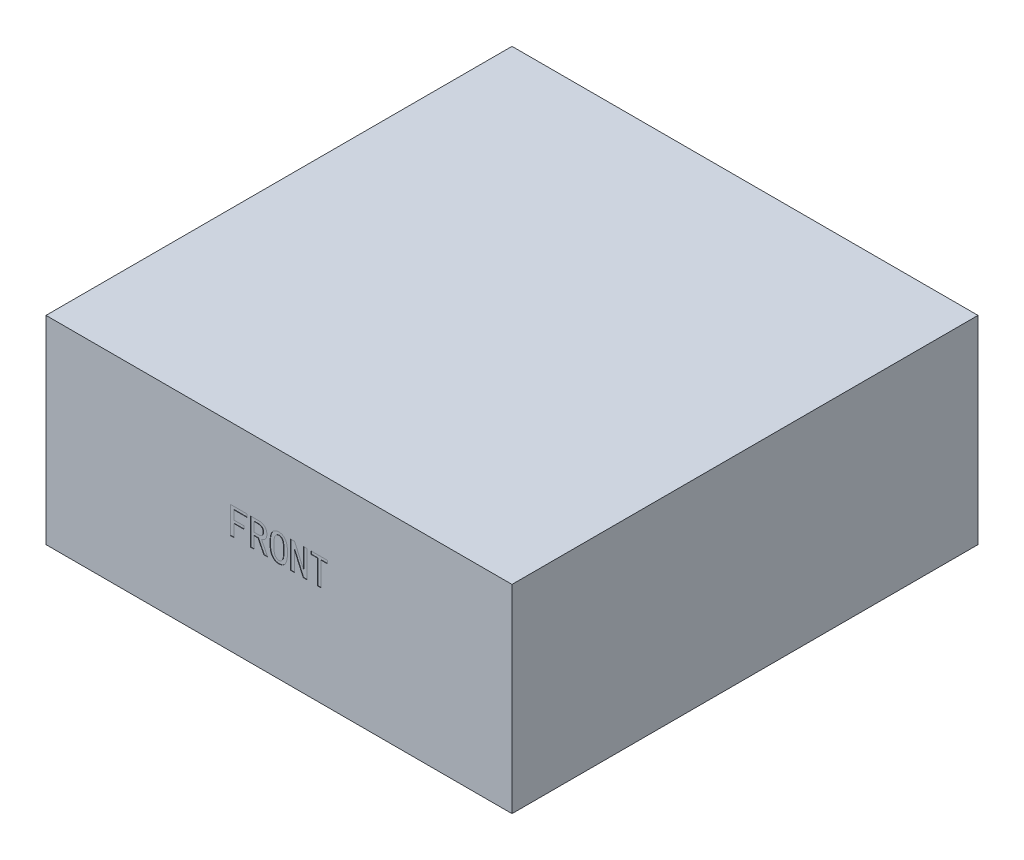
from build123d import *

# Parameters (mm, degrees)
SKETCH1_W           = 115
SKETCH1_H           = 115
BOSS_EXTRUDE1_DEPTH = 49
CUT_EXTRUDE1_DEPTH  = 0.1
SKETCH3_R           = 1.5
CUT_EXTRUDE2_DEPTH  = 10


with BuildPart() as part:
    # Sketch1 → Boss-Extrude1 (new body)
    with BuildSketch(Plane(origin=(0, 0, 0), x_dir=(1, 0, 0), z_dir=(0, 1, 0))):
        Rectangle(SKETCH1_W, SKETCH1_H)
    extrude(amount=BOSS_EXTRUDE1_DEPTH)

    # Sketch2 → Cut-Extrude1 (cut)
    with BuildSketch(Plane.XY.offset(57.5)):
        Polygon((-7.917836765, 30.623647153), (-11.116174769, 30.623647153), (-11.116174769, 28.439416321), (-8.697919205, 28.439416321), (-8.697919205, 27.698338004), (-11.116174769, 27.698338004), (-11.116174769, 24.69502061), (-12.013269574, 24.69502061), (-12.013269574, 31.364725471), (-7.917836765, 31.364725471), align=None)
        with BuildLine():
            Line((-2.808296784, 24.69502061), (-3.744395712, 24.69502061))
            Line((-3.744395712, 24.69502061), (-5.148544103, 27.581325638))
            Line((-5.148544103, 27.581325638), (-6.162651275, 27.581325638))
            Line((-6.162651275, 27.581325638), (-6.162651275, 24.69502061))
            Line((-6.162651275, 24.69502061), (-7.059746081, 24.69502061))
            Line((-7.059746081, 24.69502061), (-7.059746081, 31.364725471))
            Line((-7.059746081, 31.364725471), (-5.109539981, 31.364725471))
            add(Edge.make_bspline(
                [(-5.109539981, 31.364725471), (-5.033422241, 31.36321552), (-4.884283624, 31.36025705), (-4.665846358, 31.340727494), (-4.45885424, 31.304160913), (-4.262886168, 31.2548471), (-4.076887368, 31.193875661), (-3.903169293, 31.114522393), (-3.739054577, 31.023957299), (-3.586622204, 30.918577266), (-3.448652055, 30.797520978), (-3.327861252, 30.658008975), (-3.227422926, 30.499867995), (-3.143874152, 30.324418369), (-3.081593847, 30.131289285), (-3.03483742, 29.921040893), (-3.007693079, 29.693076761), (-3.004805189, 29.534974999), (-3.003317394, 29.453523493)],
                knots=[0, 0, 0, 0, 0.000228361, 0.00044743, 0.000657141, 0.000858251, 0.001053315, 0.00124341, 0.001430305, 0.001615044, 0.001798235, 0.001979525, 0.00216666, 0.002358574, 0.002560946, 0.002774043, 0.003003934, 0.003248224, 0.003248224, 0.003248224, 0.003248224], degree=3))
            add(Edge.make_bspline(
                [(-3.003317394, 29.453523493), (-3.004236594, 29.390390165), (-3.006030237, 29.267197519), (-3.025454571, 29.088095913), (-3.055313469, 28.91994093), (-3.097086791, 28.762601258), (-3.151593342, 28.616101913), (-3.220384865, 28.48106626), (-3.299426456, 28.356037186), (-3.420653553, 28.207891531), (-3.588089734, 28.047546476), (-3.806690348, 27.888834669), (-4.041069396, 27.768553012), (-4.20761293, 27.721662055), (-4.290453419, 27.698338004)],
                knots=[0, 0, 0, 0, 0.00018933, 0.000369442, 0.000539739, 0.000701282, 0.000857172, 0.001007701, 0.001155171, 0.001300013, 0.001580967, 0.001847979, 0.002108336, 0.002366009, 0.002366009, 0.002366009, 0.002366009], degree=3))
            Line((-4.290453419, 27.698338004), (-2.808296784, 24.69502061))
        make_face()
        with BuildLine():
            add(Edge.make_bspline(
                [(-3.900412199, 29.453523493), (-3.901748926, 29.49785105), (-3.904356853, 29.584333232), (-3.918058807, 29.710781951), (-3.944676192, 29.829563943), (-3.979689395, 29.941648265), (-4.029204658, 30.044568137), (-4.084168454, 30.142579968), (-4.154012978, 30.230821503), (-4.23149366, 30.314063254), (-4.321756192, 30.387946189), (-4.424347653, 30.452561636), (-4.540300007, 30.505247189), (-4.66873106, 30.548395909), (-4.809255351, 30.583172975), (-4.962947559, 30.607131703), (-5.129478007, 30.621721067), (-5.24481863, 30.622989931), (-5.304560591, 30.623647153)],
                knots=[0, 0, 0, 0, 0.000133028, 0.000259536, 0.000380813, 0.000497763, 0.000610867, 0.000722858, 0.000834102, 0.000947528, 0.001063501, 0.001182941, 0.00131027, 0.001444579, 0.00158893, 0.001744014, 0.00191077, 0.002089952, 0.002089952, 0.002089952, 0.002089952], degree=3))
            Line((-5.304560591, 30.623647153), (-6.162651275, 30.623647153))
            Line((-6.162651275, 30.623647153), (-6.162651275, 28.322403955))
            Line((-6.162651275, 28.322403955), (-5.070535859, 28.322403955))
            add(Edge.make_bspline(
                [(-5.070535859, 28.322403955), (-4.994665596, 28.325278445), (-4.846167618, 28.330904573), (-4.631700963, 28.380266995), (-4.431452215, 28.459145684), (-4.278021472, 28.551076939), (-4.166997245, 28.642292798), (-4.09583809, 28.724884044), (-4.034438276, 28.817808807), (-3.985709894, 28.923304629), (-3.946407327, 29.039415745), (-3.919439908, 29.167412302), (-3.903806651, 29.306747081), (-3.901571336, 29.403402305), (-3.900412199, 29.453523493)],
                knots=[0, 0, 0, 0, 0.000227358, 0.000444999, 0.000656384, 0.000870935, 0.000978584, 0.001086078, 0.001196663, 0.001311688, 0.00143366, 0.001563714, 0.001703302, 0.001853652, 0.001853652, 0.001853652, 0.001853652], degree=3))
        make_face(mode=Mode.SUBTRACT)
        with BuildLine():
            add(Edge.make_bspline(
                [(2.106222588, 28.049375102), (2.104638402, 27.901989899), (2.10158126, 27.617567687), (2.076095619, 27.207161265), (2.031695072, 26.82904424), (1.970403688, 26.482896179), (1.891842386, 26.168709294), (1.795828911, 25.886167353), (1.680457686, 25.636023899), (1.546904644, 25.41693972), (1.39678476, 25.227882136), (1.233894982, 25.063918506), (1.056291438, 24.92550274), (0.864707416, 24.811956665), (0.658556134, 24.724615825), (0.438710496, 24.662734024), (0.204547172, 24.624299596), (0.043488517, 24.619480605), (-0.039004122, 24.617012366)],
                knots=[0, 0, 0, 0, 0.000442132, 0.00085322, 0.00123291, 0.001583713, 0.001907102, 0.002203597, 0.002477629, 0.002731829, 0.002971427, 0.00320024, 0.003423611, 0.003645102, 0.003866465, 0.004093271, 0.004328864, 0.004576232, 0.004576232, 0.004576232, 0.004576232], degree=3))
            add(Edge.make_bspline(
                [(-0.039004122, 24.617012366), (-0.121500553, 24.619461841), (-0.282566612, 24.624244198), (-0.517594069, 24.663091696), (-0.739347562, 24.724661311), (-0.94821304, 24.811465061), (-1.141829149, 24.926310641), (-1.323405374, 25.063670898), (-1.490622201, 25.227714829), (-1.644998894, 25.416745077), (-1.783350279, 25.635389631), (-1.900892003, 25.886353937), (-2.002130368, 26.168221542), (-2.083356965, 26.482676242), (-2.145811299, 26.8290056), (-2.191653976, 27.207114767), (-2.218999451, 27.617515704), (-2.22178939, 27.901982841), (-2.223234954, 28.049375102)],
                knots=[0, 0, 0, 0, 0.000247368, 0.000482961, 0.000712548, 0.000936572, 0.001159307, 0.001386114, 0.001618011, 0.001860325, 0.002116817, 0.00239208, 0.002690017, 0.003014129, 0.00336519, 0.003745053, 0.004156236, 0.004598367, 0.004598367, 0.004598367, 0.004598367], degree=3))
            add(Edge.make_bspline(
                [(-2.223234954, 28.049375102), (-2.221797055, 28.196767253), (-2.219026596, 28.480753675), (-2.19168221, 28.890200387), (-2.145741574, 29.266845166), (-2.083787264, 29.610896124), (-2.001917575, 29.922344351), (-1.900792728, 30.200819234), (-1.784188051, 30.448592174), (-1.644441558, 30.662080248), (-1.49068342, 30.846771475), (-1.322820459, 31.006235125), (-1.141824641, 31.140922798), (-0.947714733, 31.252374573), (-0.739333592, 31.338201692), (-0.517347932, 31.397603951), (-0.282639025, 31.43742263), (-0.121517361, 31.440934979), (-0.039004122, 31.442733715)],
                knots=[0, 0, 0, 0, 0.000442132, 0.000851873, 0.001230302, 0.001579943, 0.001899865, 0.002195086, 0.002467744, 0.002719373, 0.002958344, 0.003187239, 0.003412308, 0.003633596, 0.003857065, 0.004086265, 0.004321859, 0.004569155, 0.004569155, 0.004569155, 0.004569155], degree=3))
            add(Edge.make_bspline(
                [(-0.039004122, 31.442733715), (0.043505595, 31.440916879), (0.204620382, 31.437369185), (0.438460465, 31.397958442), (0.65854017, 31.338245657), (0.864214402, 31.251892228), (1.05626943, 31.141722698), (1.233314852, 31.006005274), (1.396849483, 30.846601498), (1.546358274, 30.661899939), (1.68129518, 30.447931356), (1.79572828, 30.201010175), (1.891641604, 29.921856448), (1.970823367, 29.61066893), (2.031627706, 29.26680742), (2.076122742, 28.890153344), (2.10160703, 28.480701525), (2.104645443, 28.196760167), (2.106222588, 28.049375102)],
                knots=[0, 0, 0, 0, 0.000247296, 0.00048289, 0.000709305, 0.000930106, 0.00115014, 0.001371748, 0.001597517, 0.001833734, 0.002083027, 0.002354442, 0.002648207, 0.002967398, 0.003316778, 0.003695034, 0.004104681, 0.004546812, 0.004546812, 0.004546812, 0.004546812], degree=3))
        make_face()
        with BuildLine():
            add(Edge.make_bspline(
                [(1.17012366, 28.049375102), (1.168977278, 28.179886743), (1.166785118, 28.429456735), (1.151419283, 28.786062711), (1.124868433, 29.10767027), (1.086021701, 29.394031602), (1.038724051, 29.646003408), (0.978466823, 29.862111581), (0.909424785, 30.044151489), (0.825355184, 30.191731443), (0.732569272, 30.312395299), (0.638213496, 30.416827035), (0.53757346, 30.505020013), (0.431191022, 30.575712746), (0.32142593, 30.63363454), (0.205145093, 30.672042098), (0.08497742, 30.698401397), (0.002551737, 30.700564728), (-0.039004122, 30.701655397)],
                knots=[0, 0, 0, 0, 0.000391528, 0.000748698, 0.001070571, 0.001359248, 0.001615362, 0.001838994, 0.002031603, 0.002197882, 0.002346388, 0.002487486, 0.002619578, 0.002746588, 0.002869989, 0.002990593, 0.003112984, 0.003237429, 0.003237429, 0.003237429, 0.003237429], degree=3))
            add(Edge.make_bspline(
                [(-0.039004122, 30.701655397), (-0.080555875, 30.70053613), (-0.163446064, 30.698303341), (-0.284570281, 30.672034759), (-0.402300825, 30.633687961), (-0.513806475, 30.575437521), (-0.622819585, 30.504672225), (-0.727847858, 30.417593743), (-0.824785822, 30.311539897), (-0.923924964, 30.192680435), (-1.011907116, 30.044393297), (-1.085946133, 29.862679926), (-1.148438959, 29.646084929), (-1.199253455, 29.394281784), (-1.23892723, 29.107683237), (-1.267027351, 28.786105392), (-1.284203339, 28.429491941), (-1.286129065, 28.179891142), (-1.287136026, 28.049375102)],
                knots=[0, 0, 0, 0, 0.000124445, 0.000248251, 0.000370224, 0.000494912, 0.00062433, 0.000759722, 0.000902788, 0.001054849, 0.001223316, 0.00141756, 0.001641994, 0.001898677, 0.002187553, 0.002509552, 0.002866789, 0.003258317, 0.003258317, 0.003258317, 0.003258317], degree=3))
            add(Edge.make_bspline(
                [(-1.287136026, 28.049375102), (-1.286119055, 27.918859607), (-1.284170438, 27.668778862), (-1.267050694, 27.311199198), (-1.238787588, 26.987718066), (-1.199388023, 26.699166508), (-1.148324152, 26.444988861), (-1.085265087, 26.225327663), (-1.012248341, 26.038947749), (-0.923791362, 25.886167259), (-0.825317626, 25.762772497), (-0.727367115, 25.653945286), (-0.623352213, 25.562417879), (-0.514212634, 25.488577227), (-0.402328492, 25.429191077), (-0.284857724, 25.388690247), (-0.163359034, 25.363366086), (-0.08053703, 25.359852599), (-0.039004122, 25.358090684)],
                knots=[0, 0, 0, 0, 0.000391528, 0.000750208, 0.001073646, 0.001365383, 0.001623481, 0.001850687, 0.002050272, 0.00222247, 0.002377931, 0.002523111, 0.002661317, 0.002792338, 0.002917686, 0.003040128, 0.003163934, 0.003288471, 0.003288471, 0.003288471, 0.003288471], degree=3))
            add(Edge.make_bspline(
                [(-0.039004122, 25.358090684), (0.00253254, 25.359825142), (0.084889905, 25.363264162), (0.205435569, 25.388686474), (0.321452346, 25.429245854), (0.431609339, 25.488302788), (0.538123441, 25.562087821), (0.637704368, 25.654694156), (0.733123672, 25.761945098), (0.825192901, 25.887101393), (0.9097528, 26.039195265), (0.977804575, 26.225863601), (1.038614333, 26.445069857), (1.086149637, 26.699416093), (1.124733858, 26.987729887), (1.151442396, 27.311241785), (1.166754233, 27.668813837), (1.168968136, 27.918863952), (1.17012366, 28.049375102)],
                knots=[0, 0, 0, 0, 0.000124537, 0.000246928, 0.000368007, 0.000492075, 0.000620717, 0.000755692, 0.000898933, 0.001050918, 0.001220976, 0.00141897, 0.001645385, 0.001902917, 0.002194457, 0.002517769, 0.002876382, 0.00326791, 0.00326791, 0.00326791, 0.00326791], degree=3))
        make_face(mode=Mode.SUBTRACT)
        Polygon((6.942733715, 24.69502061), (5.967630665, 24.69502061), (3.822403955, 29.531531737), (3.783399833, 29.531531737), (3.783399833, 24.69502061), (2.886305028, 24.69502061), (2.886305028, 31.364725471), (3.861408077, 31.364725471), (6.006634787, 26.528214344), (6.045638909, 26.528214344), (6.045638909, 31.364725471), (6.942733715, 31.364725471), align=None)
        Polygon((11.93526133, 30.623647153), (10.375096451, 30.623647153), (10.375096451, 24.69502061), (9.478001645, 24.69502061), (9.478001645, 30.623647153), (7.917836765, 30.623647153), (7.917836765, 31.364725471), (11.93526133, 31.364725471), align=None)
    extrude(amount=-CUT_EXTRUDE1_DEPTH, mode=Mode.SUBTRACT)

    # Sketch3 → Cut-Extrude2 (cut)
    with BuildSketch(Plane.XZ):
        with Locations((-15, 42.5)):
            Circle(SKETCH3_R)
        with Locations((-15, -42.5)):
            Circle(SKETCH3_R)
    extrude(amount=-CUT_EXTRUDE2_DEPTH, mode=Mode.SUBTRACT)


solid = part.part
